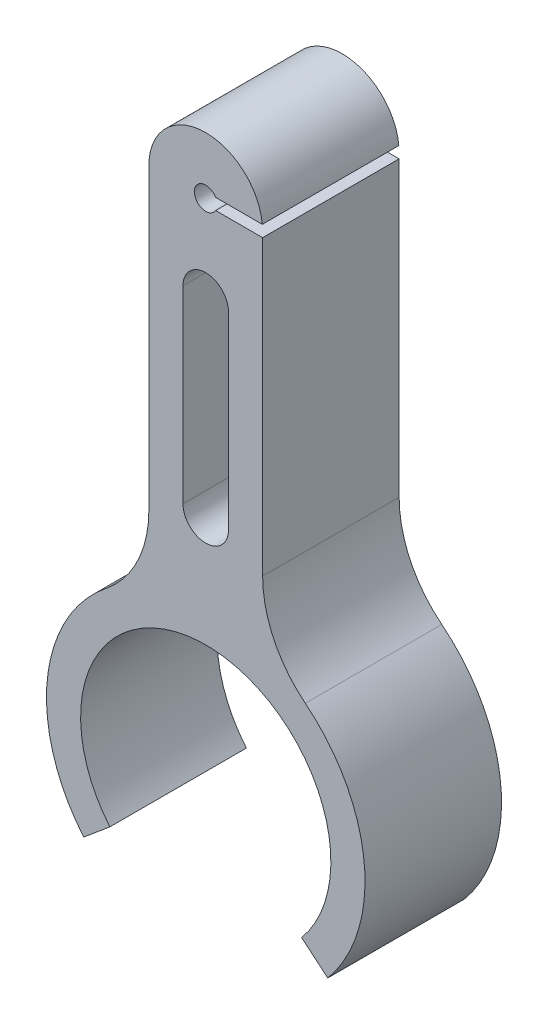
from build123d import *

# Parameters (mm, degrees)
SKETCH1_R                    = 2
BOSS_EXTRUDE1_DEPTH          = 12
SKETCH2_R                    = 2
SKETCH2_R_2                  = 1
BOSS_EXTRUDE2_DEPTH          = 3
FILLET1_R                    = 10
SKETCH3_W                    = 12
SKETCH3_H                    = 1
CUT_EXTRUDE_THIN2_DEPTH      = 10
CUT_EXTRUDE_THIN2_DEPTH_BACK = 5


with BuildPart() as part:
    # Sketch1 → Boss-Extrude1 (new body)
    with BuildSketch(Plane.XY):
        with BuildLine():
            Line((5, 13.076696831), (5, 45))
            ThreePointArc((5, 45), (0, 50), (-5, 45))
            Line((-5, 45), (-5, 13.076696831))
            ThreePointArc((-5, 13.076696831), (-13.551764697, 3.514210239), (-10.724622204, -8.999026536))
            Line((-10.724622204, -8.999026536), (-8.426488874, -7.070663707))
            ThreePointArc((-8.426488874, -7.070663707), (-3.762221577, 10.336618829), (11, 0))
            ThreePointArc((11, 0), (10.336618829, -3.762221577), (8.426488874, -7.070663707))
            Line((8.426488874, -7.070663707), (10.724622204, -8.999026536))
            ThreePointArc((10.724622204, -8.999026536), (13.551764697, 3.514210239), (5, 13.076696831))
        make_face()
        with BuildLine():
            ThreePointArc((-2, 37.335582027), (0, 39.335582027), (2, 37.335582027))
            Line((2, 37.335582027), (2, 20.741114804))
            ThreePointArc((2, 20.741114804), (0, 18.741114804), (-2, 20.741114804))
            Line((-2, 20.741114804), (-2, 37.335582027))
        make_face(mode=Mode.SUBTRACT)
        with Locations((0, 45)):
            Circle(SKETCH1_R, mode=Mode.SUBTRACT)
    extrude(amount=BOSS_EXTRUDE1_DEPTH)

    # Sketch2 → Boss-Extrude2 (add)
    with BuildSketch(Plane.XY.offset(12)):
        with Locations((0, 45)):
            Circle(SKETCH2_R)
        with Locations((0, 45)):
            Circle(SKETCH2_R_2, mode=Mode.SUBTRACT)
    extrude(amount=-BOSS_EXTRUDE2_DEPTH)

    # Fillet1
    fillet1_edges = [part.edges().sort_by_distance(p)[0] for p in [
        (5, 13.076696831, 6),
        (-5, 13.076696831, 6),
    ]]
    fillet(fillet1_edges, radius=FILLET1_R)

    # Sketch3 → Cut-Extrude-Thin2 (cut, two sides)
    with BuildSketch(Plane(origin=(5, 0, 0), x_dir=(0, 0, -1), z_dir=(1, 0, 0))) as cut_extrude_thin2_sk:
        with Locations((-6, 45)):
            Rectangle(SKETCH3_W, SKETCH3_H)
    extrude(amount=CUT_EXTRUDE_THIN2_DEPTH, mode=Mode.SUBTRACT)
    extrude(cut_extrude_thin2_sk.sketch, amount=-CUT_EXTRUDE_THIN2_DEPTH_BACK, mode=Mode.SUBTRACT)


solid = part.part
